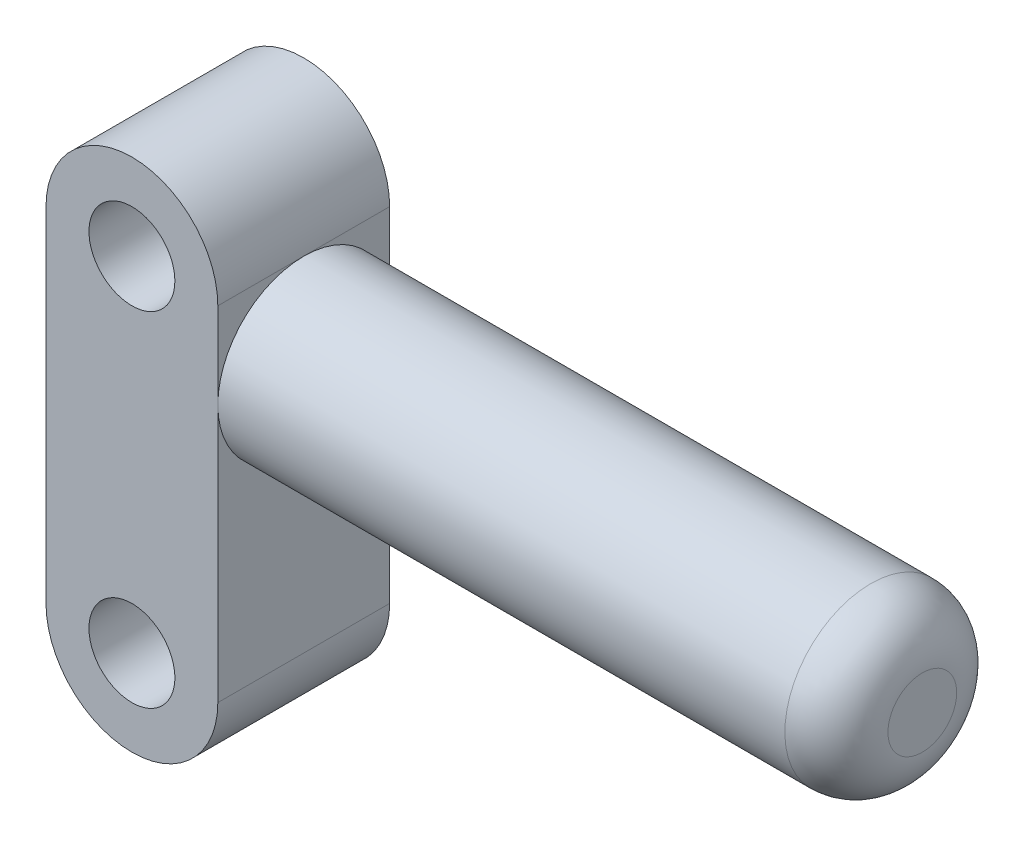
from build123d import *

# Parameters (mm, degrees)
ESQUISSE1_R        = 2.5
BOSS_EXTRU_1_DEPTH = 5
ESQUISSE2_R        = 5
BOSS_EXTRU_2_DEPTH = 36
CONG_1_R           = 3


with BuildPart() as part:
    # Esquisse1 → Boss.-Extru.1 (new, symmetric)
    with BuildSketch(Plane.XY):
        with BuildLine():
            Line((5, 10), (5, -10))
            ThreePointArc((5, -10), (0, -15), (-5, -10))
            Line((-5, -10), (-5, 10))
            ThreePointArc((-5, 10), (0, 15), (5, 10))
        make_face()
        with Locations((0, 10)):
            Circle(ESQUISSE1_R, mode=Mode.SUBTRACT)
        with Locations((0, -10)):
            Circle(ESQUISSE1_R, mode=Mode.SUBTRACT)
    extrude(amount=BOSS_EXTRU_1_DEPTH, both=True)

    # Esquisse2 → Boss.-Extru.2 (add)
    with BuildSketch(Plane(origin=(5, 0, 0), x_dir=(0, 0, -1), z_dir=(1, 0, 0))):
        with Locations((0, 5)):
            Circle(ESQUISSE2_R)
    extrude(amount=BOSS_EXTRU_2_DEPTH)

    # Congé1
    cong_1_edges = [part.edges().sort_by_distance(p)[0] for p in [
        (41, 5, 5),
    ]]
    fillet(cong_1_edges, radius=CONG_1_R)


solid = part.part
